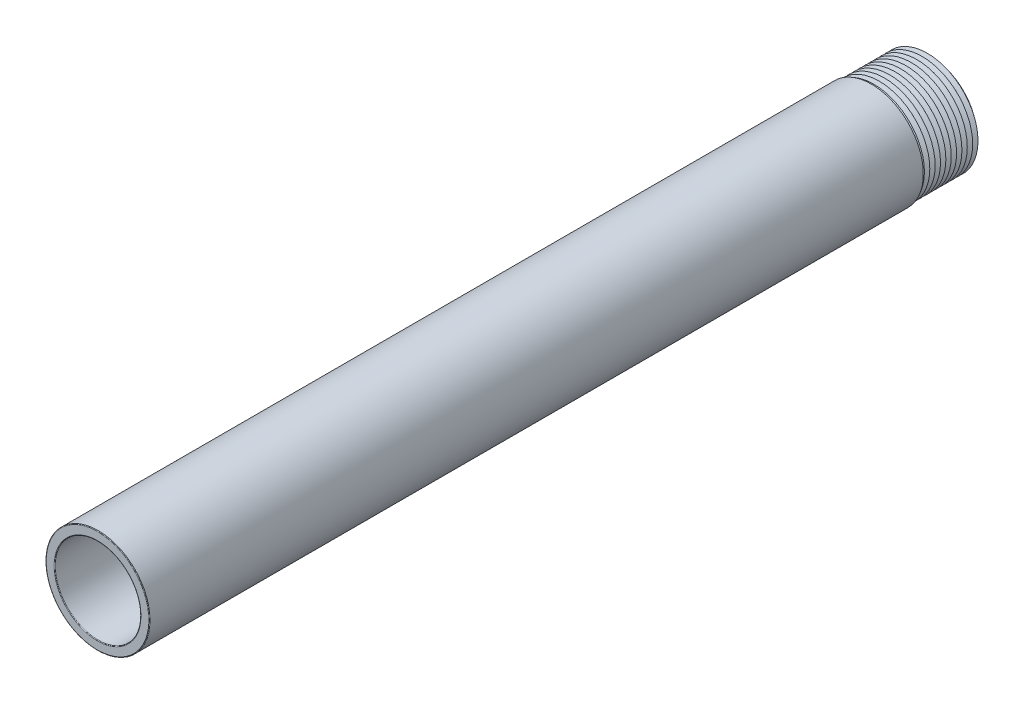
from build123d import *

# Parameters (mm, degrees)
SKETCH1_R          = 11.0744
SKETCH1_R_2        = 9.144
EXTRUDE1_DEPTH     = 177.8
CUT_EXTRUDE1_DEPTH = 2.54
FILLET1_R          = 0.127


with BuildPart() as part:
    # Sketch1 → Extrude1 (new body)
    with BuildSketch(Plane.XY):
        Circle(SKETCH1_R)
        Circle(SKETCH1_R_2, mode=Mode.SUBTRACT)
    extrude(amount=EXTRUDE1_DEPTH)

    # Sketch6 → Cut-Extrude1 (cut)
    with BuildSketch(Plane(origin=(-11.0744, 0, 0), x_dir=(0, 0, -1), z_dir=(1, 0, 0))):
        with BuildLine():
            Line((-88.9, -1.2192), (-63.5, -1.2192))
            ThreePointArc((-63.5, -1.2192), (-62.2808, 0), (-63.5, 1.2192))
            Line((-63.5, 1.2192), (-88.9, 1.2192))
            ThreePointArc((-88.9, 1.2192), (-90.1192, 0), (-88.9, -1.2192))
        make_face()
        with BuildLine():
            Line((-50.8, 1.2192), (-25.4, 1.2192))
            ThreePointArc((-25.4, 1.2192), (-24.1808, 0), (-25.4, -1.2192))
            Line((-25.4, -1.2192), (-50.8, -1.2192))
            ThreePointArc((-50.8, -1.2192), (-52.0192, 0), (-50.8, 1.2192))
        make_face()
        with BuildLine():
            Line((-127, -1.2192), (-101.6, -1.2192))
            ThreePointArc((-101.6, -1.2192), (-100.3808, 0), (-101.6, 1.2192))
            Line((-101.6, 1.2192), (-127, 1.2192))
            ThreePointArc((-127, 1.2192), (-128.2192, 0), (-127, -1.2192))
        make_face()
        with BuildLine():
            Line((-165.1, -1.2192), (-139.7, -1.2192))
            ThreePointArc((-139.7, -1.2192), (-138.4808, 0), (-139.7, 1.2192))
            Line((-139.7, 1.2192), (-165.1, 1.2192))
            ThreePointArc((-165.1, 1.2192), (-166.3192, 0), (-165.1, -1.2192))
        make_face()
    extrude(amount=CUT_EXTRUDE1_DEPTH, mode=Mode.SUBTRACT)

    # Sketch9 → Cut-Revolve1 (revolve, cut)
    with BuildSketch(Plane(origin=(0, 0, 0), x_dir=(0, 0, -1), z_dir=(1, 0, 0)), mode=Mode.PRIVATE) as cut_revolve1_sk:
        Polygon((-12.7, 9.906), (-12.186735611, 10.795), (-11.673471207, 9.906), (-11.557, 9.906), (-11.043735611, 10.795), (-10.530471207, 9.906), (-10.414, 9.906), (-9.900735611, 10.795), (-9.387471207, 9.906), (-9.271, 9.906), (-8.757735611, 10.795), (-8.244471207, 9.906), (-8.128, 9.906), (-7.614735611, 10.795), (-7.101471207, 9.906), (-6.985, 9.906), (-6.471735611, 10.795), (-5.958471207, 9.906), (-5.842, 9.906), (-5.328735611, 10.795), (-4.815471207, 9.906), (-4.699, 9.906), (-4.185735611, 10.795), (-3.672471207, 9.906), (-3.556, 9.906), (-3.042735611, 10.795), (-2.529471207, 9.906), (-2.413, 9.906), (-1.899735611, 10.795), (-1.386471207, 9.906), (-1.27, 9.906), (-0.756735611, 10.795), (-0.243471207, 9.906), (0, 9.906), (0, 11.366390924), (-12.7, 11.366390924), align=None)
    revolve(cut_revolve1_sk.sketch.rotate(Axis((0, 0, 177.8), (0, 0, -1)), 90), axis=Axis((0, 0, 177.8), (0, 0, -1)), mode=Mode.SUBTRACT)  # turned: the seam where the file's is

    # Fillet1
    fillet1_edges = [part.edges().sort_by_distance(p)[0] for p in [
        (-9.062355508, -1.2192, 76.2),
        (-9.062355508, 1.2192, 76.2),
        (-9.906, 0, 0),
        (-11.007083479, 1.2192, 76.2),
        (-11.0744, 0, 62.2808),
        (-11.007083479, -1.2192, 76.2),
        (-11.007083479, 1.2192, 76.2),
        (-9.062355508, 1.2192, 38.1),
        (-9.144, 0, 24.1808),
        (-9.062355508, -1.2192, 38.1),
        (-9.062355508, 1.2192, 38.1),
        (-11.007083479, 1.2192, 38.1),
        (-11.0744, 0, 24.1808),
        (-11.007083479, -1.2192, 38.1),
        (-11.0744, 0, 177.8),
        (-11.007083479, 1.2192, 38.1),
        (-9.144, 0, 0),
        (-9.144, 0, 177.8),
        (-9.062355508, 1.2192, 114.3),
        (-9.144, 0, 100.3808),
        (-9.062355508, -1.2192, 114.3),
        (-9.062355508, 1.2192, 114.3),
        (-11.007083479, 1.2192, 114.3),
        (-11.0744, 0, 100.3808),
        (-11.007083479, -1.2192, 114.3),
        (-11.007083479, 1.2192, 114.3),
        (-9.062355508, 1.2192, 152.4),
        (-9.144, 0, 138.4808),
        (-9.062355508, -1.2192, 152.4),
        (-9.062355508, 1.2192, 152.4),
        (-11.007083479, 1.2192, 152.4),
        (-11.0744, 0, 138.4808),
        (-11.007083479, -1.2192, 152.4),
        (-11.007083479, 1.2192, 152.4),
        (-9.062355508, 1.2192, 76.2),
        (-9.144, 0, 62.2808),
    ]]
    fillet(fillet1_edges, radius=FILLET1_R)


solid = part.part
